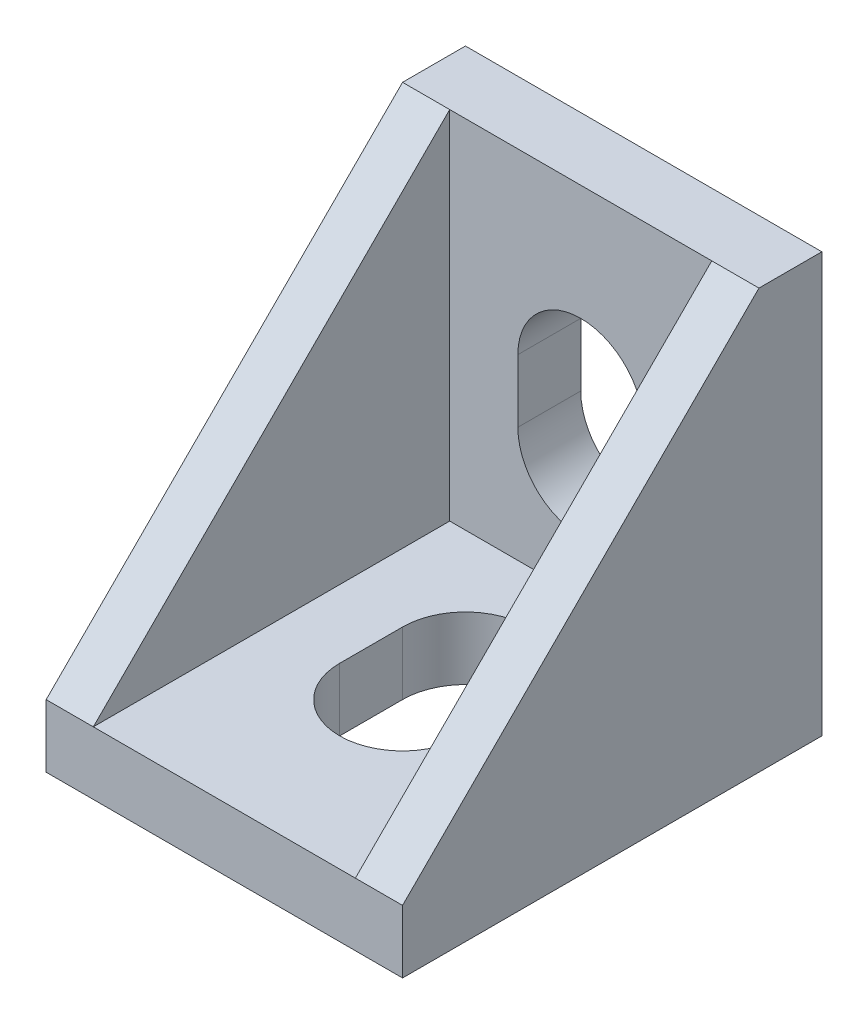
from build123d import *

# Parameters (mm, degrees)
BOSS_EXTRUDE3_DEPTH       = 17
SHELL4_T                  = -2.25
SHELL4_THICKNESS_2_FACE_W = 17.75
SHELL4_THICKNESS_2_FACE_H = 12.5
SHELL4_THICKNESS_2_DEPTH  = 0.75
SHELL4_THICKNESS_3_FACE_W = 17
SHELL4_THICKNESS_3_FACE_H = 12.5
SHELL4_THICKNESS_3_DEPTH  = 0.75
CUT_EXTRUDE1_DEPTH        = 29.08914381
CUT_EXTRUDE2_DEPTH        = 29.08914381
BOSS_EXTRUDE4_DEPTH       = 1
BOSS_EXTRUDE5_DEPTH       = 1
BOSS_EXTRUDE6_DEPTH       = 1
BOSS_EXTRUDE7_DEPTH       = 1


with BuildPart() as part:
    # Sketch4 → Boss-Extrude3 (new body)
    with BuildSketch(Plane(origin=(0, 0, 0), x_dir=(0, 0, -1), z_dir=(1, 0, 0))):
        Polygon((7, 10), (-10, -7), (-10, -10), (10, -10), (10, 10), align=None)
    extrude(amount=BOSS_EXTRUDE3_DEPTH)

    # Shell4
    shell4_openings = [part.faces().sort_by_distance(p)[0] for p in [
        (8.5, 10, -8.5),
        (8.5, -8.5, 10),
        (8.5, 1.5, 1.5),
    ]]
    offset(amount=SHELL4_T, openings=shell4_openings, kind=Kind.INTERSECTION)

    # Shell4 thickness 2 face (on inner face of the shell) → Shell4 thickness 2 (add)
    with BuildSketch(Plane(origin=(8.5, -7.75, 1.125), x_dir=(0, 0, -1), z_dir=(0, -1, 0))):
        Rectangle(SHELL4_THICKNESS_2_FACE_W, SHELL4_THICKNESS_2_FACE_H)
    extrude(amount=-SHELL4_THICKNESS_2_DEPTH)

    # Shell4 thickness 3 face (on inner face of the shell) → Shell4 thickness 3 (add)
    with BuildSketch(Plane(origin=(8.5, 1.5, -7.75), x_dir=(0, -1, 0), z_dir=(0, 0, -1))):
        Rectangle(SHELL4_THICKNESS_3_FACE_W, SHELL4_THICKNESS_3_FACE_H)
    extrude(amount=-SHELL4_THICKNESS_3_DEPTH)

    # Sketch5 → Cut-Extrude1 (cut, through all)
    with BuildSketch(Plane(origin=(0, 0, -10), x_dir=(-1, 0, 0), z_dir=(0, 0, -1))):
        with BuildLine():
            Line((-11.5, 1.5), (-11.5, -1.5))
            ThreePointArc((-11.5, -1.5), (-8.5, -4.5), (-5.5, -1.5))
            Line((-5.5, -1.5), (-5.5, 1.5))
            ThreePointArc((-5.5, 1.5), (-8.5, 4.5), (-11.5, 1.5))
        make_face()
    extrude(amount=-CUT_EXTRUDE1_DEPTH, mode=Mode.SUBTRACT)

    # Sketch8 → Cut-Extrude2 (cut, through all)
    with BuildSketch(Plane(origin=(0, -10, 0), x_dir=(-1, 0, 0), z_dir=(0, -1, 0))):
        with BuildLine():
            Line((-11.5, 1.5), (-11.5, -1.5))
            ThreePointArc((-11.5, -1.5), (-8.5, -4.5), (-5.5, -1.5))
            Line((-5.5, -1.5), (-5.5, 1.5))
            ThreePointArc((-5.5, 1.5), (-8.5, 4.5), (-11.5, 1.5))
        make_face()
    extrude(amount=-CUT_EXTRUDE2_DEPTH, mode=Mode.SUBTRACT)

    # Sketch9 → Boss-Extrude4 (add)
    with BuildSketch(Plane(origin=(0, 0, -10), x_dir=(-1, 0, 0), z_dir=(0, 0, -1))):
        with BuildLine():
            Line((-9.525, 8.125), (-7.475, 8.125))
            ThreePointArc((-7.475, 8.125), (-6.6, 7.25), (-7.475, 6.375))
            Line((-7.475, 6.375), (-9.525, 6.375))
            ThreePointArc((-9.525, 6.375), (-10.4, 7.25), (-9.525, 8.125))
        make_face()
    extrude(amount=BOSS_EXTRUDE4_DEPTH)

    # Sketch10 → Boss-Extrude5 (add)
    with BuildSketch(Plane(origin=(0, 0, -10), x_dir=(-1, 0, 0), z_dir=(0, 0, -1))):
        with BuildLine():
            Line((-9.525, -6.375), (-7.475, -6.375))
            ThreePointArc((-7.475, -6.375), (-6.6, -7.25), (-7.475, -8.125))
            Line((-7.475, -8.125), (-9.525, -8.125))
            ThreePointArc((-9.525, -8.125), (-10.4, -7.25), (-9.525, -6.375))
        make_face()
    extrude(amount=BOSS_EXTRUDE5_DEPTH)

    # Sketch12 → Boss-Extrude6 (add)
    with BuildSketch(Plane(origin=(-0.843813019, -10, -7.7592784), x_dir=(-1, 0, 0), z_dir=(0, -1, 0))):
        with BuildLine():
            Line((-10.368813019, 0.3657216), (-8.318813019, 0.3657216))
            ThreePointArc((-8.318813019, 0.3657216), (-7.443813019, -0.5092784), (-8.318813019, -1.3842784))
            Line((-8.318813019, -1.3842784), (-10.368813019, -1.3842784))
            ThreePointArc((-10.368813019, -1.3842784), (-11.243813019, -0.5092784), (-10.368813019, 0.3657216))
        make_face()
    extrude(amount=BOSS_EXTRUDE6_DEPTH)

    # Sketch14 → Boss-Extrude7 (add)
    with BuildSketch(Plane(origin=(-0.843813019, -10, -7.7592784), x_dir=(-1, 0, 0), z_dir=(0, -1, 0))):
        with BuildLine():
            Line((-10.368813019, -14.1342784), (-8.318813019, -14.1342784))
            ThreePointArc((-8.318813019, -14.1342784), (-7.443813019, -15.0092784), (-8.318813019, -15.8842784))
            Line((-8.318813019, -15.8842784), (-10.368813019, -15.8842784))
            ThreePointArc((-10.368813019, -15.8842784), (-11.243813019, -15.0092784), (-10.368813019, -14.1342784))
        make_face()
    extrude(amount=BOSS_EXTRUDE7_DEPTH)


solid = part.part
